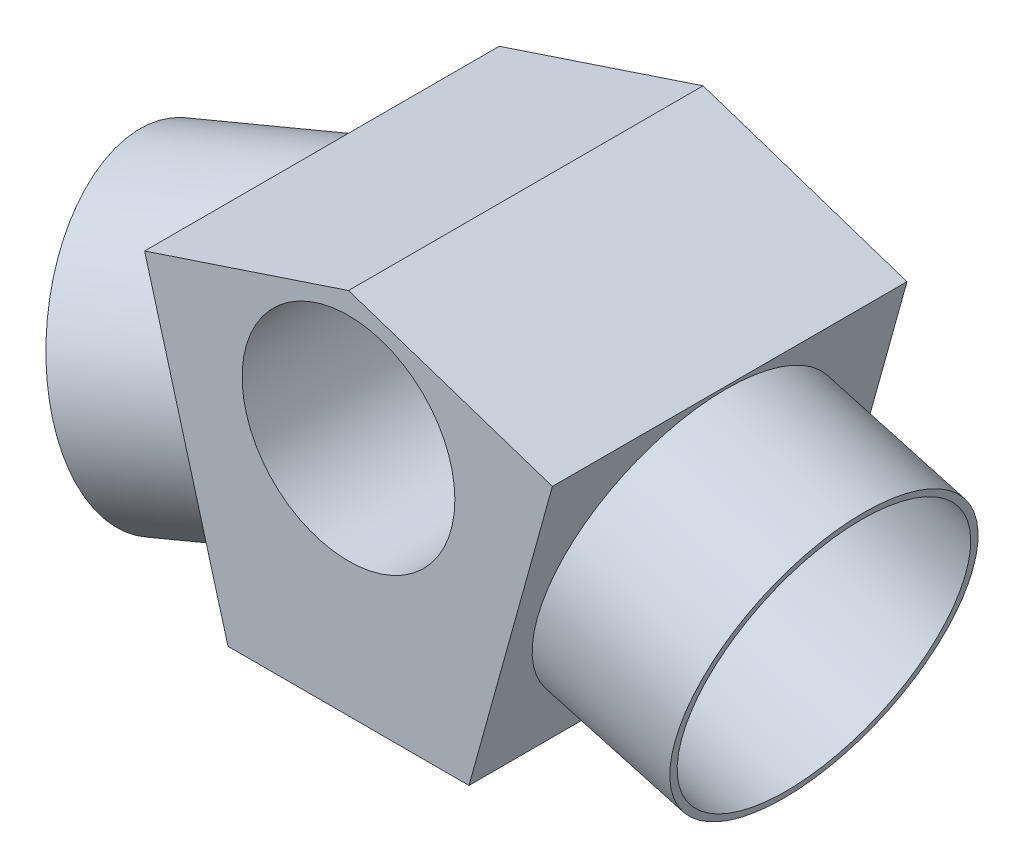
from build123d import *

# Parameters (mm, degrees)
SKETCH2_R                = 7.5
BOSS_EXTRUDE1_DEPTH      = 25
SKETCH14_R               = 10.5
SKETCH14_R_2             = 10
EXTRUDE_THIN3_DEPTH      = 3
EXTRUDE_THIN3_DEPTH_BACK = 12
SKETCH8_R                = 10
CUT_EXTRUDE4_DEPTH       = 13
SKETCH12_R               = 10.5
SKETCH12_R_2             = 10
EXTRUDE_THIN2_DEPTH      = 12


with BuildPart() as part:
    # Sketch2 → Boss-Extrude1 (new body)
    with BuildSketch(Plane.XY):
        Polygon((0, 9.022413356), (-14.374271139, 4.248669099), (-8.495026865, -16.951200871), (8.495026865, -16.951200871), (14.374271139, 4.248669099), align=None)
        Circle(SKETCH2_R, mode=Mode.SUBTRACT)
    extrude(amount=-BOSS_EXTRUDE1_DEPTH)

    # Sketch14 → Extrude-Thin3 (add, two sides)
    with BuildSketch(Plane(origin=(-8.98162527, -2.490825133, 2.158943025), x_dir=(0.267238376, -0.963630453, 0), z_dir=(0.938775452, 0.260345474, -0.225656566))) as extrude_thin3_sk:
        with Locations((3.064496194, 15.047052931)):
            Circle(SKETCH14_R)
        with Locations((3.064496194, 15.047052931)):
            Circle(SKETCH14_R_2, mode=Mode.SUBTRACT)
    extrude(amount=EXTRUDE_THIN3_DEPTH)
    extrude(extrude_thin3_sk.sketch, amount=-EXTRUDE_THIN3_DEPTH_BACK)

    # Sketch8 → Cut-Extrude4 (cut)
    with BuildSketch(Plane(origin=(21.957149201, -6.089256391, 0), x_dir=(0, 0, -1), z_dir=(0.963630453, -0.267238376, 0))):
        with Locations((12.31580825, -2.819568794)):
            Circle(SKETCH8_R)
    extrude(amount=-CUT_EXTRUDE4_DEPTH, mode=Mode.SUBTRACT)

    # Sketch12 → Extrude-Thin2 (add)
    with BuildSketch(Plane(origin=(21.957149201, -6.089256391, 0), x_dir=(0, 0, -1), z_dir=(0.963630453, -0.267238376, 0))):
        with Locations((12.31580825, -2.819568794)):
            Circle(SKETCH12_R)
        with Locations((12.31580825, -2.819568794)):
            Circle(SKETCH12_R_2, mode=Mode.SUBTRACT)
    extrude(amount=-EXTRUDE_THIN2_DEPTH)


solid = part.part
